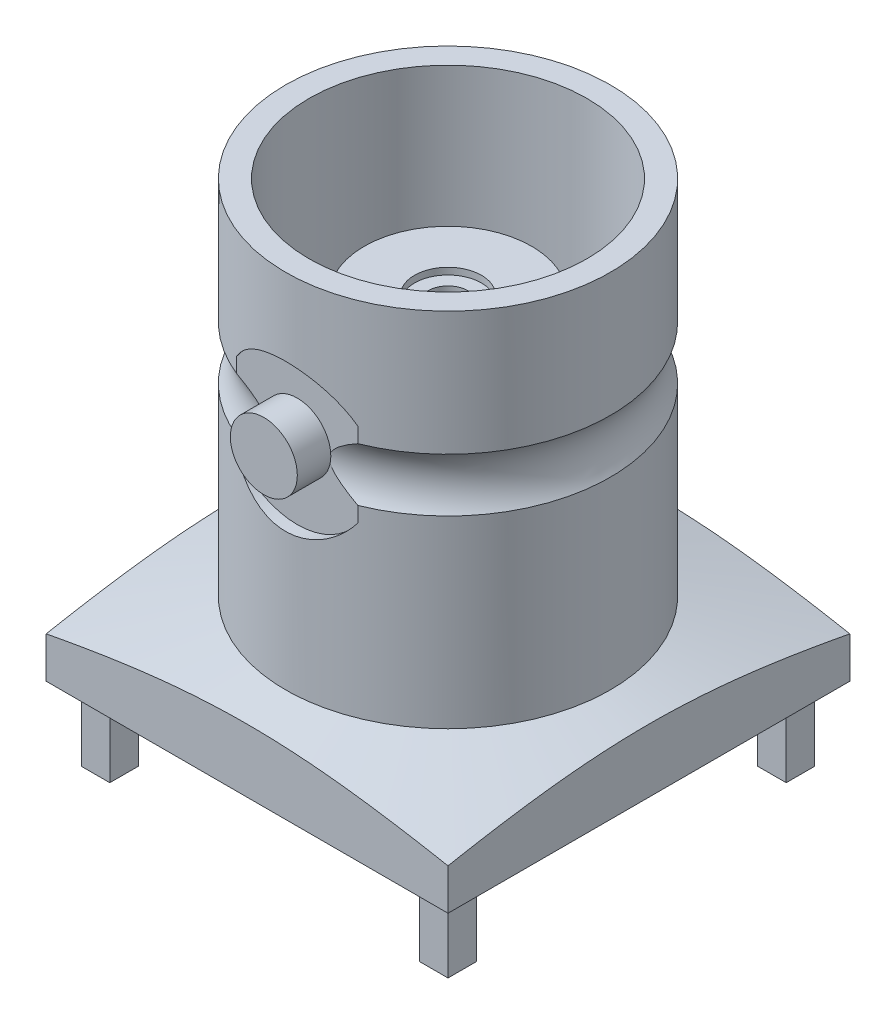
from build123d import *

# Parameters (mm, degrees)
ESQUISSE2_W                  = 22
ESQUISSE2_H                  = 22
ESQUISSE2_W_2                = 12
ESQUISSE2_H_2                = 12
ENL_V_MAT_EXTRU_4_DEPTH      = 14
ENL_V_MAT_EXTRU_4_DEPTH_BACK = 1
ESQUISSE3_W                  = 0.85
ESQUISSE3_H                  = 0.85
BOSS_EXTRU_1_DEPTH           = 2.2
ESQUISSE4_R                  = 0.6
ENL_V_MAT_EXTRU_5_DEPTH      = 2
ESQUISSE5_R                  = 2.2
ENL_V_MAT_EXTRU_6_DEPTH      = 1.5
ESQUISSE6_R                  = 1
BOSS_EXTRU_2_DEPTH           = 1
ESQUISSE7_R                  = 0.5
BOSS_EXTRU_3_DEPTH           = 2.4
CHANFREIN1_SIZE              = 0.2


with BuildPart() as part:
    # Esquisse1 → Révolution1 (revolve)
    with BuildSketch(Plane.XY):
        with BuildLine():
            Line((0, 0), (-10, 0))
            Line((-10, 0), (-10, 0.820061659))
            Line((-10, 0.820061659), (-4.85, 2.2))
            Line((-4.85, 2.2), (-4.85, 7.701564029))
            ThreePointArc((-4.85, 7.701564029), (-4.6, 8.5), (-4.85, 9.298435971))
            Line((-4.85, 9.298435971), (-4.85, 13))
            Line((-4.85, 13), (-4.15, 13))
            Line((-4.15, 13), (-4.15, 5))
            Line((-4.15, 5), (-2.5, 5))
            Line((-2.5, 5), (-2.5, 10))
            Line((-2.5, 10), (-1, 10))
            Line((-1, 10), (-1, 9.8))
            Line((-1, 9.8), (0, 9.8))
            Line((0, 9.8), (0, 0))
        make_face()
    revolve(axis=Axis((0, 9.8, 0), (0, -1, 0)))

    # Esquisse2 → Enlèv. mat.-Extru.4 (cut, two sides)
    with BuildSketch(Plane(origin=(0, 0, 0), x_dir=(1, 0, 0), z_dir=(0, 1, 0))) as enl_v_mat_extru_4_sk:
        Rectangle(ESQUISSE2_W, ESQUISSE2_H)
        Rectangle(ESQUISSE2_W_2, ESQUISSE2_H_2, mode=Mode.SUBTRACT)
    extrude(amount=ENL_V_MAT_EXTRU_4_DEPTH, mode=Mode.SUBTRACT)
    extrude(enl_v_mat_extru_4_sk.sketch, amount=-ENL_V_MAT_EXTRU_4_DEPTH_BACK, mode=Mode.SUBTRACT)

    # Esquisse3 → Boss.-Extru.1 (add)
    with BuildSketch(Plane.XZ):
        with Locations((5.05, -5.05)):
            Rectangle(ESQUISSE3_W, ESQUISSE3_H)
        with Locations((-5.05, -5.05)):
            Rectangle(ESQUISSE3_W, ESQUISSE3_H)
        with Locations((-5.05, 5.05)):
            Rectangle(ESQUISSE3_W, ESQUISSE3_H)
        with Locations((5.05, 5.05)):
            Rectangle(ESQUISSE3_W, ESQUISSE3_H)
    extrude(amount=BOSS_EXTRU_1_DEPTH)

    # Esquisse4 → Enlèv. mat.-Extru.5 (cut)
    with BuildSketch(Plane(origin=(0, 9.8, 0), x_dir=(1, 0, 0), z_dir=(0, 1, 0))):
        Circle(ESQUISSE4_R)
    extrude(amount=-ENL_V_MAT_EXTRU_5_DEPTH, mode=Mode.SUBTRACT)

    # Esquisse5 → Enlèv. mat.-Extru.6 (cut)
    with BuildSketch(Plane.XY.offset(6)):
        with Locations((0, 8.5)):
            Circle(ESQUISSE5_R)
    enl_v_mat_extru_6 = extrude(amount=-ENL_V_MAT_EXTRU_6_DEPTH, mode=Mode.SUBTRACT)

    # Esquisse6 → Boss.-Extru.2 (add)
    with BuildSketch(Plane.XY.offset(4.5)):
        with Locations((0, 8.574177758)):
            Circle(ESQUISSE6_R)
    boss_extru_2 = extrude(amount=BOSS_EXTRU_2_DEPTH)

    # Symétrie1: Enlèv. mat.-Extru.6, Boss.-Extru.2 across plane
    add(enl_v_mat_extru_6.mirror(Plane.XY), mode=Mode.SUBTRACT)
    add(boss_extru_2.mirror(Plane.XY))

    # Esquisse7 → Boss.-Extru.3 (add)
    with BuildSketch(Plane.XZ):
        Circle(ESQUISSE7_R)
    extrude(amount=BOSS_EXTRU_3_DEPTH)

    # Chanfrein1
    chanfrein1_edges = [part.edges().sort_by_distance(p)[0] for p in [
        (-0.5, -2.4, 0),
    ]]
    chamfer(chanfrein1_edges, length=CHANFREIN1_SIZE)


solid = part.part
